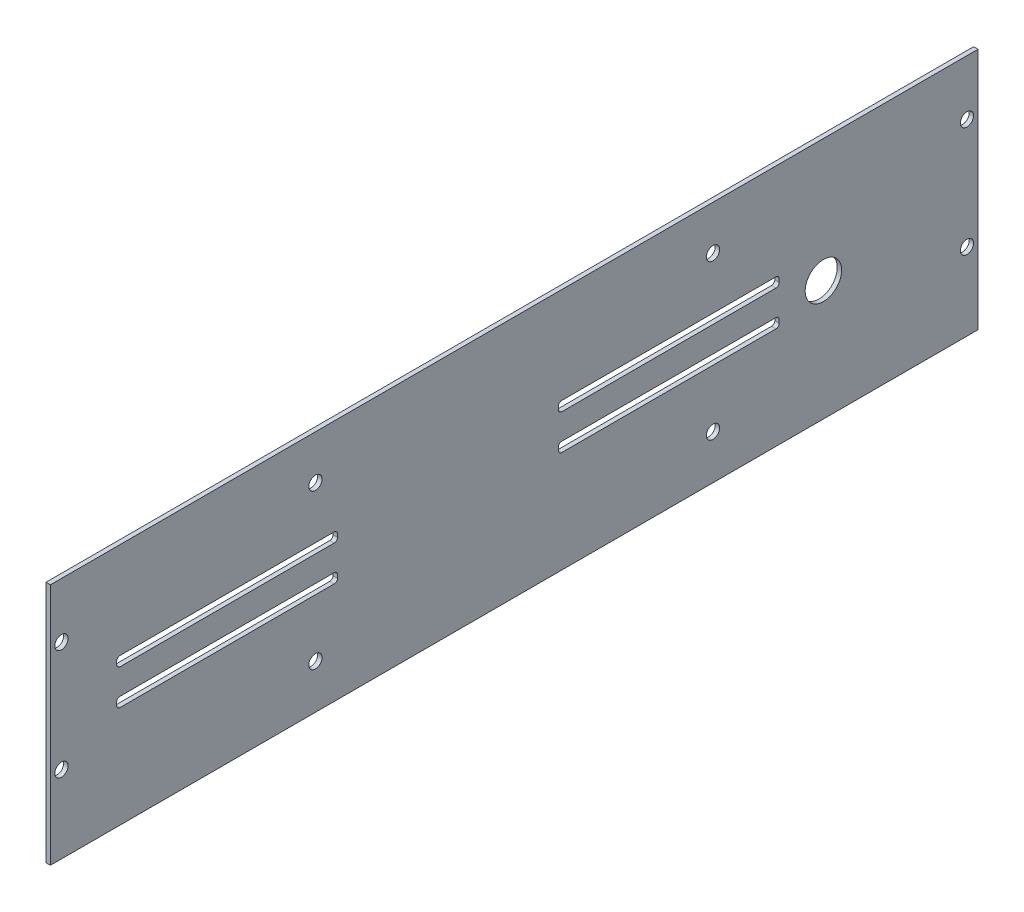
from build123d import *

# Parameters (mm, degrees)
SKETCH1_W           = 420
SKETCH1_H           = 110
BOSS_EXTRUDE1_DEPTH = 2
SKETCH2_W           = 100
SKETCH2_H           = 4.4
CUT_EXTRUDE1_DEPTH  = 2
FILLET1_R           = 1.5
CUT_EXTRUDE2_REACH  = 4
SKETCH3_R           = 3
CUT_EXTRUDE3_REACH  = 4
SKETCH4_R           = 3
SKETCH4_R_2         = 8.25


with BuildPart() as part:
    # Sketch1 → Boss-Extrude1 (new body)
    with BuildSketch(Plane(origin=(23.948254466, 0, 0), x_dir=(0, 0, -1), z_dir=(1, 0, 0))):
        with Locations((-184.692172039, 45)):
            Rectangle(SKETCH1_W, SKETCH1_H)
    extrude(amount=BOSS_EXTRUDE1_DEPTH)

    # Sketch2 → Cut-Extrude1 (cut)
    with BuildSketch(Plane(origin=(25.948254466, 0, 0), x_dir=(0, 0, -1), z_dir=(1, 0, 0))):
        with Locations((-314.692172039, 54.3)):
            Rectangle(SKETCH2_W, SKETCH2_H)
        with Locations((-314.692172039, 38.3)):
            Rectangle(SKETCH2_W, SKETCH2_H)
        with Locations((-114.692172039, 54.3)):
            Rectangle(SKETCH2_W, SKETCH2_H)
        with Locations((-114.692172039, 38.3)):
            Rectangle(SKETCH2_W, SKETCH2_H)
    extrude(amount=-CUT_EXTRUDE1_DEPTH, mode=Mode.SUBTRACT)

    # Fillet1
    fillet1_edges = [part.edges().sort_by_distance(p)[0] for p in [
        (24.948254466, 52.1, 364.692172039),
        (24.948254466, 56.5, 364.692172039),
        (24.948254466, 56.5, 264.692172039),
        (24.948254466, 52.1, 264.692172039),
        (24.948254466, 36.1, 364.692172039),
        (24.948254466, 40.5, 364.692172039),
        (24.948254466, 40.5, 264.692172039),
        (24.948254466, 36.1, 264.692172039),
        (24.948254466, 56.5, 64.692172039),
        (24.948254466, 52.1, 64.692172039),
        (24.948254466, 52.1, 164.692172039),
        (24.948254466, 56.5, 164.692172039),
        (24.948254466, 36.1, 164.692172039),
        (24.948254466, 40.5, 164.692172039),
        (24.948254466, 40.5, 64.692172039),
        (24.948254466, 36.1, 64.692172039),
    ]]
    fillet(fillet1_edges, radius=FILLET1_R)

    # Sketch3 → Cut-Extrude2 (cut, up to next)
    with BuildSketch(Plane(origin=(25.948254466, 0, 0), x_dir=(0, 0, -1), z_dir=(1, 0, 0)), mode=Mode.PRIVATE) as cut_extrude2_sk1:
        with Locations((-389.692172039, 75)):
            Circle(SKETCH3_R)
    cut_extrude2_tool1 = extrude(cut_extrude2_sk1.sketch, amount=-CUT_EXTRUDE2_REACH, mode=Mode.PRIVATE) & part.part
    add(cut_extrude2_tool1.solids().sort_by_distance((25.948254, 75, 389.692172))[0], mode=Mode.SUBTRACT)
    # Sketch3 → Cut-Extrude2 (cut, up to next)
    with BuildSketch(Plane(origin=(25.948254466, 0, 0), x_dir=(0, 0, -1), z_dir=(1, 0, 0)), mode=Mode.PRIVATE) as cut_extrude2_sk2:
        with Locations((-389.692172039, 25)):
            Circle(SKETCH3_R)
    cut_extrude2_tool2 = extrude(cut_extrude2_sk2.sketch, amount=-CUT_EXTRUDE2_REACH, mode=Mode.PRIVATE) & part.part
    add(cut_extrude2_tool2.solids().sort_by_distance((25.948254, 25, 389.692172))[0], mode=Mode.SUBTRACT)
    # Sketch3 → Cut-Extrude2 (cut, up to next)
    with BuildSketch(Plane(origin=(25.948254466, 0, 0), x_dir=(0, 0, -1), z_dir=(1, 0, 0)), mode=Mode.PRIVATE) as cut_extrude2_sk3:
        with Locations((20.307827961, 75)):
            Circle(SKETCH3_R)
    cut_extrude2_tool3 = extrude(cut_extrude2_sk3.sketch, amount=-CUT_EXTRUDE2_REACH, mode=Mode.PRIVATE) & part.part
    add(cut_extrude2_tool3.solids().sort_by_distance((25.948254, 75, -20.307828))[0], mode=Mode.SUBTRACT)
    # Sketch3 → Cut-Extrude2 (cut, up to next)
    with BuildSketch(Plane(origin=(25.948254466, 0, 0), x_dir=(0, 0, -1), z_dir=(1, 0, 0)), mode=Mode.PRIVATE) as cut_extrude2_sk4:
        with Locations((20.307827961, 25)):
            Circle(SKETCH3_R)
    cut_extrude2_tool4 = extrude(cut_extrude2_sk4.sketch, amount=-CUT_EXTRUDE2_REACH, mode=Mode.PRIVATE) & part.part
    add(cut_extrude2_tool4.solids().sort_by_distance((25.948254, 25, -20.307828))[0], mode=Mode.SUBTRACT)

    # Sketch4 → Cut-Extrude3 (cut, up to next)
    with BuildSketch(Plane(origin=(25.948254466, 0, 0), x_dir=(0, 0, -1), z_dir=(1, 0, 0)), mode=Mode.PRIVATE) as cut_extrude3_sk1:
        with Locations((-274.692172039, 10)):
            Circle(SKETCH4_R)
    cut_extrude3_tool1 = extrude(cut_extrude3_sk1.sketch, amount=-CUT_EXTRUDE3_REACH, mode=Mode.PRIVATE) & part.part
    add(cut_extrude3_tool1.solids().sort_by_distance((25.948254, 10, 274.692172))[0], mode=Mode.SUBTRACT)
    # Sketch4 → Cut-Extrude3 (cut, up to next)
    with BuildSketch(Plane(origin=(25.948254466, 0, 0), x_dir=(0, 0, -1), z_dir=(1, 0, 0)), mode=Mode.PRIVATE) as cut_extrude3_sk2:
        with Locations((-94.692172039, 10)):
            Circle(SKETCH4_R)
    cut_extrude3_tool2 = extrude(cut_extrude3_sk2.sketch, amount=-CUT_EXTRUDE3_REACH, mode=Mode.PRIVATE) & part.part
    add(cut_extrude3_tool2.solids().sort_by_distance((25.948254, 10, 94.692172))[0], mode=Mode.SUBTRACT)
    # Sketch4 → Cut-Extrude3 (cut, up to next)
    with BuildSketch(Plane(origin=(25.948254466, 0, 0), x_dir=(0, 0, -1), z_dir=(1, 0, 0)), mode=Mode.PRIVATE) as cut_extrude3_sk3:
        with Locations((-44.692172039, 44.3)):
            Circle(SKETCH4_R_2)
    cut_extrude3_tool3 = extrude(cut_extrude3_sk3.sketch, amount=-CUT_EXTRUDE3_REACH, mode=Mode.PRIVATE) & part.part
    add(cut_extrude3_tool3.solids().sort_by_distance((25.948254, 44.3, 44.692172))[0], mode=Mode.SUBTRACT)
    # Sketch4 → Cut-Extrude3 (cut, up to next)
    with BuildSketch(Plane(origin=(25.948254466, 0, 0), x_dir=(0, 0, -1), z_dir=(1, 0, 0)), mode=Mode.PRIVATE) as cut_extrude3_sk4:
        with Locations((-274.692172039, 80)):
            Circle(SKETCH4_R)
    cut_extrude3_tool4 = extrude(cut_extrude3_sk4.sketch, amount=-CUT_EXTRUDE3_REACH, mode=Mode.PRIVATE) & part.part
    add(cut_extrude3_tool4.solids().sort_by_distance((25.948254, 80, 274.692172))[0], mode=Mode.SUBTRACT)
    # Sketch4 → Cut-Extrude3 (cut, up to next)
    with BuildSketch(Plane(origin=(25.948254466, 0, 0), x_dir=(0, 0, -1), z_dir=(1, 0, 0)), mode=Mode.PRIVATE) as cut_extrude3_sk5:
        with Locations((-94.692172039, 80)):
            Circle(SKETCH4_R)
    cut_extrude3_tool5 = extrude(cut_extrude3_sk5.sketch, amount=-CUT_EXTRUDE3_REACH, mode=Mode.PRIVATE) & part.part
    add(cut_extrude3_tool5.solids().sort_by_distance((25.948254, 80, 94.692172))[0], mode=Mode.SUBTRACT)


solid = part.part
